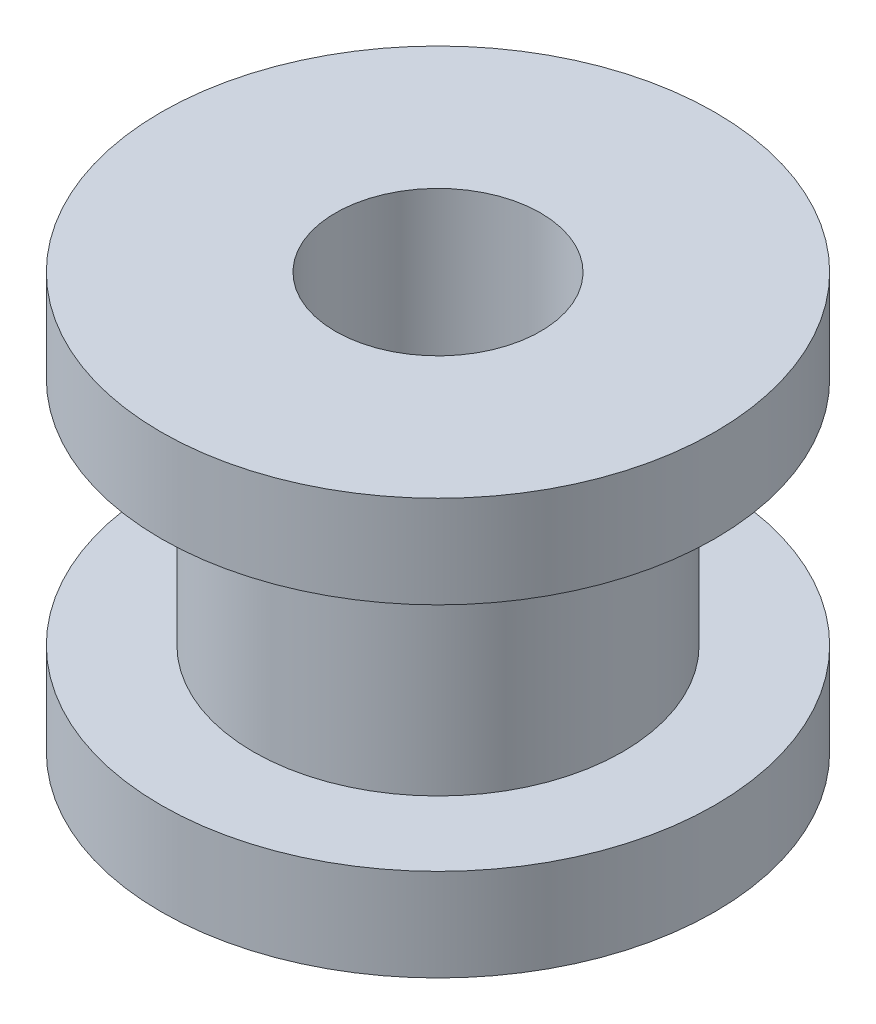
from build123d import *

# Parameters (mm, degrees)
SKETCH1_R           = 4
BOSS_EXTRUDE1_DEPTH = 5
SKETCH2_R           = 6
BOSS_EXTRUDE2_DEPTH = 2
SKETCH3_R           = 2.2225
CUT_EXTRUDE1_DEPTH  = 10


with BuildPart() as part:
    # Sketch1 → Boss-Extrude1 (new body)
    with BuildSketch(Plane(origin=(0, 0, 0), x_dir=(1, 0, 0), z_dir=(0, 1, 0))):
        Circle(SKETCH1_R)
    extrude(amount=BOSS_EXTRUDE1_DEPTH)

    # Sketch2 → Boss-Extrude2 (add)
    with BuildSketch(Plane(origin=(0, 5, 0), x_dir=(1, 0, 0), z_dir=(0, 1, 0))):
        Circle(SKETCH2_R)
    boss_extrude2 = extrude(amount=BOSS_EXTRUDE2_DEPTH)

    # Mirror1: Boss-Extrude2 across plane
    add(boss_extrude2.mirror(Plane(origin=(0, 2.5, 0), x_dir=(0, 0, 1), z_dir=(0, -1, 0))))

    # Sketch3 → Cut-Extrude1 (cut, through all)
    with BuildSketch(Plane(origin=(0, 7, 0), x_dir=(1, 0, 0), z_dir=(0, 1, 0))):
        Circle(SKETCH3_R)
    extrude(amount=-CUT_EXTRUDE1_DEPTH, mode=Mode.SUBTRACT)


solid = part.part
